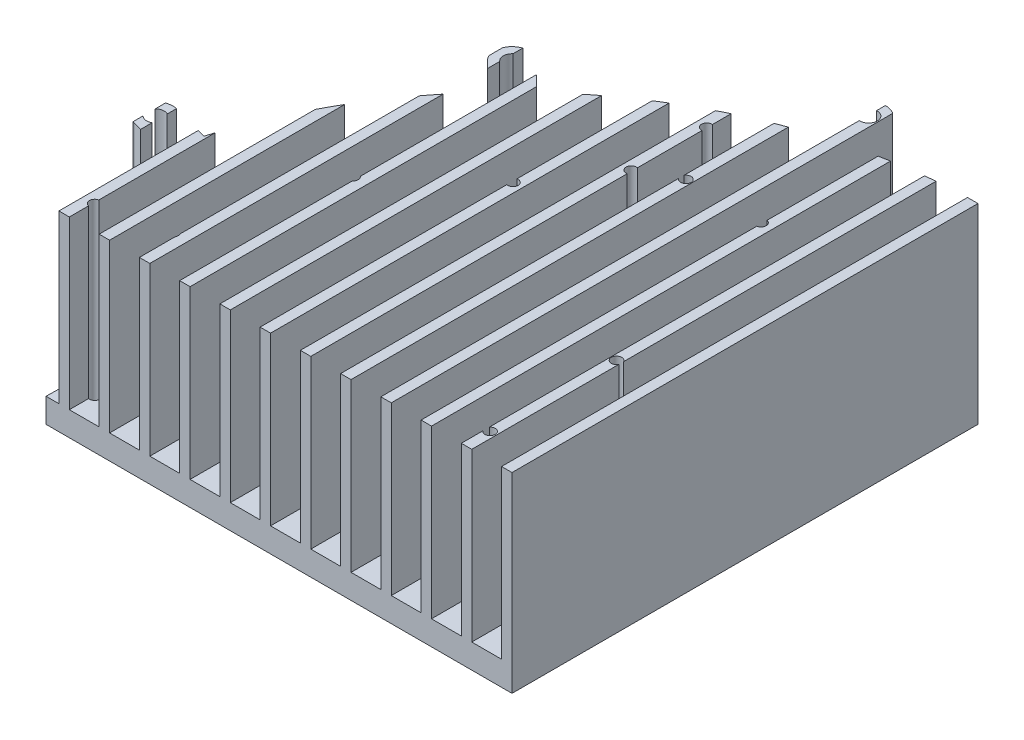
from build123d import *

# Parameters (mm, degrees)
BOSS_EXTRUDE1_DEPTH = 1000
CUT_EXTRUDE3_DEPTH  = 100
SKETCH3_6_R         = 1.5
SKETCH3_6_R_2       = 2.5
SKETCH3_6_R_3       = 1.501016752
CUT_EXTRUDE4_DEPTH  = 100


with BuildPart() as part:
    # Sketch1 → Boss-Extrude1 (new body)
    with BuildSketch(Plane.XY):
        Polygon((11.571428571, 55), (11.571428571, 7), (3, 7), (3, 55), (0, 55), (0, 7), (0, 0), (165, 0), (165, 7), (165, 10), (165, 55), (162, 55), (162, 7), (153.428571429, 7), (153.428571429, 55), (150.428571429, 55), (150.428571429, 7), (141.857142857, 7), (141.857142857, 55), (138.857142857, 55), (138.857142857, 7), (130.285714286, 7), (130.285714286, 55), (127.285714286, 55), (127.285714286, 7), (118.714285714, 7), (118.714285714, 55), (115.714285714, 55), (115.714285714, 7), (107.142857143, 7), (107.142857143, 55), (104.142857143, 55), (104.142857143, 7), (95.571428571, 7), (95.571428571, 55), (92.571428571, 55), (92.571428571, 7), (84, 7), (84, 55), (81, 55), (81, 7), (72.428571429, 7), (72.428571429, 55), (69.428571429, 55), (69.428571429, 7), (60.857142857, 7), (60.857142857, 55), (57.857142857, 55), (57.857142857, 7), (49.285714286, 7), (49.285714286, 55), (46.285714286, 55), (46.285714286, 7), (37.714285714, 7), (37.714285714, 55), (34.714285714, 55), (34.714285714, 7), (26.142857143, 7), (26.142857143, 55), (23.142857143, 55), (23.142857143, 7), (14.571428571, 7), (14.571428571, 55), align=None)
    extrude(amount=BOSS_EXTRUDE1_DEPTH)

    # Sketch3 → Cut-Extrude3 (cut)
    with BuildSketch(Plane.XZ):
        with BuildLine():
            Line((135.172029065, 203.361980458), (132.300867592, 192.646659963))
            ThreePointArc((132.300867592, 192.646659963), (126.177143235, 189.111126057), (122.641609329, 195.234850414))
            Line((122.641609329, 195.234850414), (125.512770802, 205.950170909))
            ThreePointArc((125.512770802, 205.950170909), (98, 217.952595893), (73.849209656, 235.778141844))
            Line((73.849209656, 235.778141844), (66.005050634, 227.933982822))
            ThreePointArc((66.005050634, 227.933982822), (58.933982822, 227.933982822), (58.933982822, 235.005050634))
            Line((58.933982822, 235.005050634), (66.778141844, 242.849209656))
            ThreePointArc((66.778141844, 242.849209656), (48.952595893, 267), (36.950170909, 294.512770802))
            Line((36.950170909, 294.512770802), (26.234850414, 291.641609329))
            ThreePointArc((26.234850414, 291.641609329), (20.111126057, 295.177143235), (23.646659963, 301.300867592))
            Line((23.646659963, 301.300867592), (34.361980458, 304.172029065))
            ThreePointArc((34.361980458, 304.172029065), (31.843147719, 318.991579341), (31, 334))
            Line((31, 334), (165, 334))
            Line((165, 334), (165, 1000))
            Line((165, 1000), (0, 1000))
            Line((0, 1000), (0, 0))
            Line((0, 0), (165, 0))
            Line((165, 0), (165, 200))
            ThreePointArc((165, 200), (149.991579341, 200.843147719), (135.172029065, 203.361980458))
        make_face()
    extrude(amount=-CUT_EXTRUDE3_DEPTH, mode=Mode.SUBTRACT)

    # Sketch3_6 → Cut-Extrude4 (cut)
    with BuildSketch(Plane.XZ):
        with Locations((117, 236)):
            Circle(SKETCH3_6_R)
        with Locations((106.834, 241.544)):
            Circle(SKETCH3_6_R)
        with Locations((127.47123846, 193.940755188)):
            Circle(SKETCH3_6_R_2)
        with Locations((62.469516728, 231.469516728)):
            Circle(SKETCH3_6_R_2)
        with Locations((24.940755188, 296.47123846)):
            Circle(SKETCH3_6_R_2)
        with Locations((159, 206)):
            Circle(SKETCH3_6_R)
        with Locations((159.945, 224.958)):
            Circle(SKETCH3_6_R)
        with Locations((138.59, 236)):
            Circle(SKETCH3_6_R)
        with Locations((107, 220)):
            Circle(SKETCH3_6_R)
        with Locations((92.864, 261.61)):
            Circle(SKETCH3_6_R)
        with Locations((74.576, 273.548)):
            Circle(SKETCH3_6_R)
        with Locations((68.48, 283.2)):
            Circle(SKETCH3_6_R)
        with Locations((51, 276)):
            Circle(SKETCH3_6_R)
        with Locations((152.097, 291.028)):
            Circle(SKETCH3_6_R)
        with Locations((133.3, 304.5)):
            Circle(SKETCH3_6_R)
        with Locations((66.702, 306.822)):
            Circle(SKETCH3_6_R)
        with Locations((56.542, 323.078)):
            Circle(SKETCH3_6_R)
        with Locations((38, 327)):
            Circle(SKETCH3_6_R)
        with Locations((124, 325)):
            Circle(SKETCH3_6_R)
        with Locations((158, 321)):
            Circle(SKETCH3_6_R_3)
        with Locations((151.6, 326.9)):
            Circle(SKETCH3_6_R)
    extrude(amount=-CUT_EXTRUDE4_DEPTH, mode=Mode.SUBTRACT)


solid = part.part
